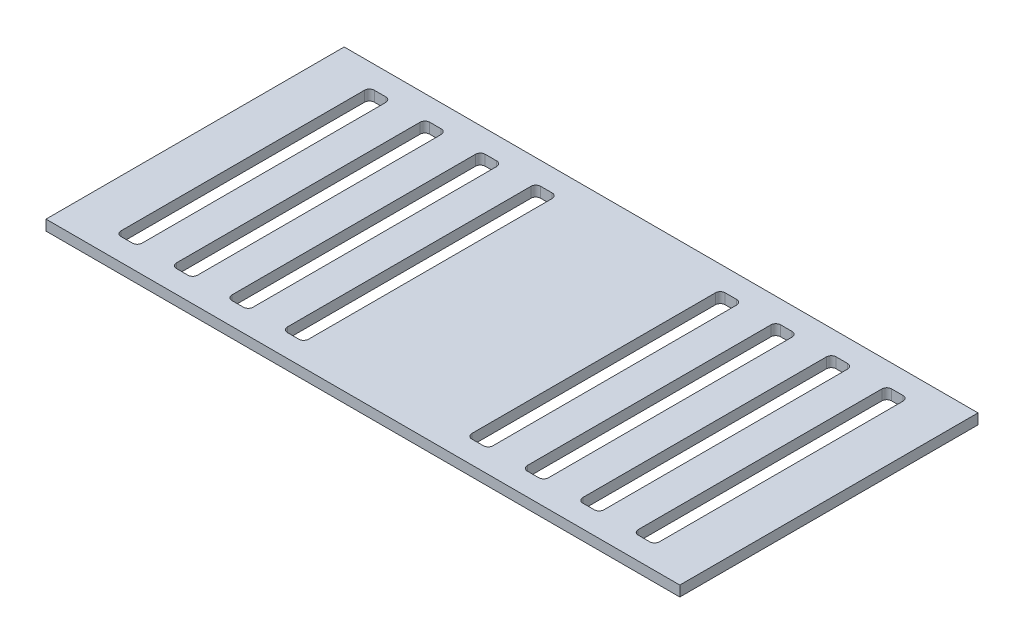
from build123d import *

# Parameters (mm, degrees)
SKETCH1_W            = 914
SKETCH1_H            = 430
BOSS_EXTRUDE1_DEPTH  = 15
CUT_EXTRUDE2_DEPTH   = 16
LPATTERN1_COUNT      = 4
LPATTERN1_PITCH      = 80
MIRROR1_COPY_1_DEPTH = 16
MIRROR1_COPY_2_DEPTH = 16
MIRROR1_COPY_3_DEPTH = 16


with BuildPart() as part:
    # Sketch1 → Boss-Extrude1 (new body)
    with BuildSketch(Plane(origin=(0, 0, 0), x_dir=(1, 0, 0), z_dir=(0, 1, 0))):
        Rectangle(SKETCH1_W, SKETCH1_H)
    extrude(amount=BOSS_EXTRUDE1_DEPTH)

    # Sketch2 → Cut-Extrude2 (cut, through all)
    with BuildSketch(Plane(origin=(0, 15, 0), x_dir=(1, 0, 0), z_dir=(0, 1, 0))):
        with BuildLine():
            Line((364.726860249, -182.685298289), (381.301805569, -182.685298289))
            ThreePointArc((381.301805569, -182.685298289), (386.251553037, -180.635045758), (388.301805569, -175.685298289))
            Line((388.301805569, -175.685298289), (388.301805569, 175.685298289))
            ThreePointArc((388.301805569, 175.685298289), (386.251553037, 180.635045758), (381.301805569, 182.685298289))
            Line((381.301805569, 182.685298289), (364.726860249, 182.685298289))
            ThreePointArc((364.726860249, 182.685298289), (359.77711278, 180.635045758), (357.726860249, 175.685298289))
            Line((357.726860249, 175.685298289), (357.726860249, -175.685298289))
            ThreePointArc((357.726860249, -175.685298289), (359.77711278, -180.635045758), (364.726860249, -182.685298289))
        make_face()
    cut_extrude2 = extrude(amount=-CUT_EXTRUDE2_DEPTH, mode=Mode.SUBTRACT)

    # LPattern1: Cut-Extrude2 ×4
    with Locations(*[(-i * LPATTERN1_PITCH, 0, 0) for i in range(1, LPATTERN1_COUNT)]):
        add(cut_extrude2, mode=Mode.SUBTRACT)

    # Mirror1: Cut-Extrude2 across plane
    add(cut_extrude2.mirror(Plane(origin=(0, 0, 0), x_dir=(0, 0, 1), z_dir=(1, 0, 0))), mode=Mode.SUBTRACT)

    # Mirror1 copy 1 sketch → Mirror1 copy 1 (cut, through all)
    with BuildSketch(Plane(origin=(80, 15, 0), x_dir=(-1, 0, 0), z_dir=(0, 1, 0))):
        with BuildLine():
            Line((364.726860249, 182.685298289), (381.301805569, 182.685298289))
            ThreePointArc((381.301805569, 182.685298289), (386.251553037, 180.635045758), (388.301805569, 175.685298289))
            Line((388.301805569, 175.685298289), (388.301805569, -175.685298289))
            ThreePointArc((388.301805569, -175.685298289), (386.251553037, -180.635045758), (381.301805569, -182.685298289))
            Line((381.301805569, -182.685298289), (364.726860249, -182.685298289))
            ThreePointArc((364.726860249, -182.685298289), (359.77711278, -180.635045758), (357.726860249, -175.685298289))
            Line((357.726860249, -175.685298289), (357.726860249, 175.685298289))
            ThreePointArc((357.726860249, 175.685298289), (359.77711278, 180.635045758), (364.726860249, 182.685298289))
        make_face()
    extrude(amount=-MIRROR1_COPY_1_DEPTH, mode=Mode.SUBTRACT)

    # Mirror1 copy 2 sketch → Mirror1 copy 2 (cut, through all)
    with BuildSketch(Plane(origin=(160, 15, 0), x_dir=(-1, 0, 0), z_dir=(0, 1, 0))):
        with BuildLine():
            Line((364.726860249, 182.685298289), (381.301805569, 182.685298289))
            ThreePointArc((381.301805569, 182.685298289), (386.251553037, 180.635045758), (388.301805569, 175.685298289))
            Line((388.301805569, 175.685298289), (388.301805569, -175.685298289))
            ThreePointArc((388.301805569, -175.685298289), (386.251553037, -180.635045758), (381.301805569, -182.685298289))
            Line((381.301805569, -182.685298289), (364.726860249, -182.685298289))
            ThreePointArc((364.726860249, -182.685298289), (359.77711278, -180.635045758), (357.726860249, -175.685298289))
            Line((357.726860249, -175.685298289), (357.726860249, 175.685298289))
            ThreePointArc((357.726860249, 175.685298289), (359.77711278, 180.635045758), (364.726860249, 182.685298289))
        make_face()
    extrude(amount=-MIRROR1_COPY_2_DEPTH, mode=Mode.SUBTRACT)

    # Mirror1 copy 3 sketch → Mirror1 copy 3 (cut, through all)
    with BuildSketch(Plane(origin=(240, 15, 0), x_dir=(-1, 0, 0), z_dir=(0, 1, 0))):
        with BuildLine():
            Line((364.726860249, 182.685298289), (381.301805569, 182.685298289))
            ThreePointArc((381.301805569, 182.685298289), (386.251553037, 180.635045758), (388.301805569, 175.685298289))
            Line((388.301805569, 175.685298289), (388.301805569, -175.685298289))
            ThreePointArc((388.301805569, -175.685298289), (386.251553037, -180.635045758), (381.301805569, -182.685298289))
            Line((381.301805569, -182.685298289), (364.726860249, -182.685298289))
            ThreePointArc((364.726860249, -182.685298289), (359.77711278, -180.635045758), (357.726860249, -175.685298289))
            Line((357.726860249, -175.685298289), (357.726860249, 175.685298289))
            ThreePointArc((357.726860249, 175.685298289), (359.77711278, 180.635045758), (364.726860249, 182.685298289))
        make_face()
    extrude(amount=-MIRROR1_COPY_3_DEPTH, mode=Mode.SUBTRACT)


solid = part.part
